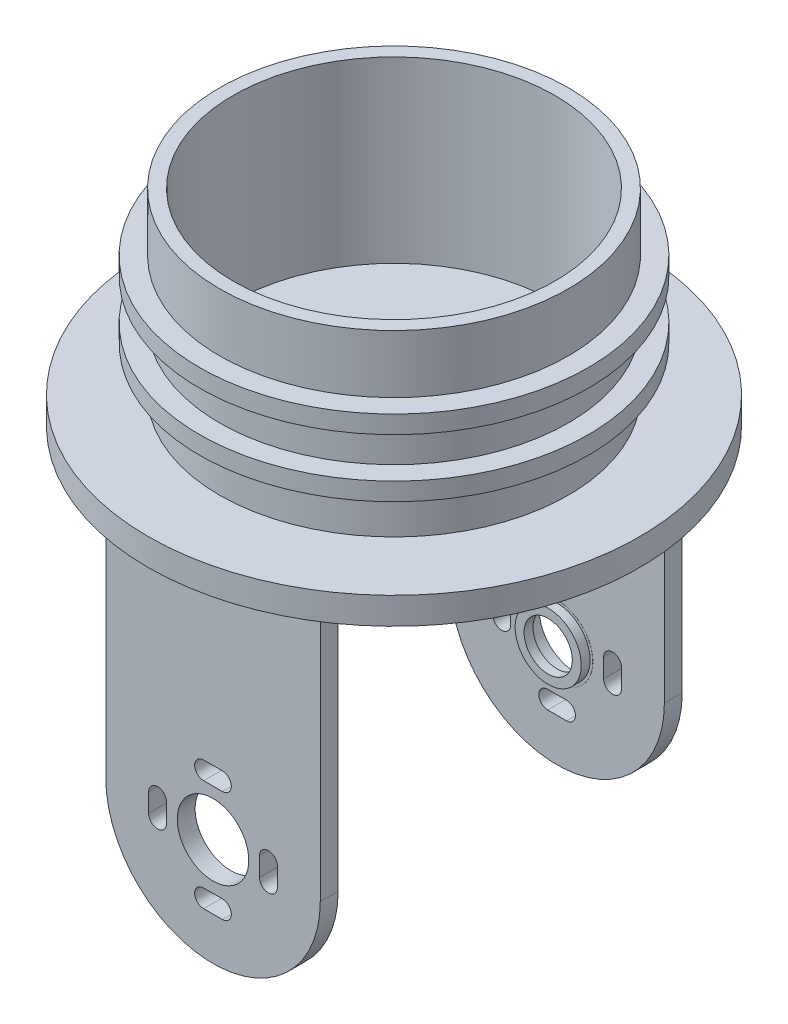
from build123d import *

# Parameters (mm, degrees)
SKETCH_1_R               = 19.5
SKETCH_1_R_2             = 18
EXTRUDE_1_DEPTH          = 20
SKETCH_3_R               = 27.5
EXTRUDE_2_DEPTH          = 3
SKETCH_25_R              = 21.75
SKETCH_25_R_2            = 19.5
EXTRUDE_12_DEPTH         = 2
EXTRUDE_START            = -1
SKETCH_26_R              = 21.75
SKETCH_26_R_2            = 19.5
EXTRUDE_13_DEPTH         = 2
SKETCH_28_R              = 4
EXTRUDE_14_DEPTH         = 2
PATTERN_LINEAR_1_COUNT   = 2
PATTERN_LINEAR_1_PITCH   = 38.5
SKETCH_30_W              = 11
SKETCH_30_H              = 7
EXTRUDE_16_DEPTH         = 10
SKETCH_29_W              = 9
SKETCH_29_H              = 5
CUT_EXTRUDE_2_DEPTH      = 10
CUT_EXTRUDE_2_DEPTH_BACK = 10
SKETCH_31_R              = 3.7
SKETCH_31_R_2            = 2.7
EXTRUDE_17_DEPTH         = 1
SKETCH_32_R              = 4
SKETCH_32_R_2            = 3.7
EXTRUDE_18_DEPTH         = 0.01
SKETCH_33_R              = 6.3
SKETCH_33_R_2            = 4.8
EXTRUDE_19_DEPTH         = 10.5
SKETCH_35_R              = 4.8
CUT_EXTRUDE_3_DEPTH      = 8
SKETCH_36_W              = 2
SKETCH_36_H              = 3.879537943
CUT_EXTRUDE_4_DEPTH      = 3


with BuildPart() as part:
    # 草圖1 → 填料-伸長1 (new body)
    with BuildSketch(Plane(origin=(0, 0, 0), x_dir=(1, 0, 0), z_dir=(0, 1, 0))):
        Circle(SKETCH_1_R)
        Circle(SKETCH_1_R_2, mode=Mode.SUBTRACT)
    extrude(amount=EXTRUDE_1_DEPTH)

    # 草圖3 → 填料-伸長2 (add)
    with BuildSketch(Plane.XZ):
        Circle(SKETCH_3_R)
    extrude(amount=EXTRUDE_2_DEPTH)

    # 草圖25 → 填料-伸長12 (add)
    with BuildSketch(Plane(origin=(0, 7, 0), x_dir=(-1, 0, 0), z_dir=(0, -1, 0))):
        Circle(SKETCH_25_R)
        Circle(SKETCH_25_R_2, mode=Mode.SUBTRACT)
    extrude(amount=EXTRUDE_12_DEPTH)

    # 草圖26 → 填料-伸長13 (add)
    with BuildSketch(Plane(origin=(0, 10.5, 0), x_dir=(-1, 0, 0), z_dir=(0, -1, 0)).offset(EXTRUDE_START)):
        Circle(SKETCH_26_R)
        Circle(SKETCH_26_R_2, mode=Mode.SUBTRACT)
    extrude(amount=-EXTRUDE_13_DEPTH)

    # 草圖28 → 填料-伸長14 (add)
    with BuildSketch(Plane.XY.offset(-18.25)):
        with BuildLine():
            Line((-12, -3), (12, -3))
            Line((12, -3), (12, -33))
            ThreePointArc((12, -33), (0, -45), (-12, -33))
            Line((-12, -33), (-12, -3))
        make_face()
        with Locations((0, -33)):
            Circle(SKETCH_28_R, mode=Mode.SUBTRACT)
        with BuildLine():
            Line((-1.05, -25.8), (1.05, -25.8))
            ThreePointArc((1.05, -25.8), (2.05, -26.8), (1.05, -27.8))
            Line((1.05, -27.8), (-1.05, -27.8))
            ThreePointArc((-1.05, -27.8), (-2.05, -26.8), (-1.05, -25.8))
        make_face(mode=Mode.SUBTRACT)
        with BuildLine():
            Line((7.2, -31.95), (7.2, -34.05))
            ThreePointArc((7.2, -34.05), (6.2, -35.05), (5.2, -34.05))
            Line((5.2, -34.05), (5.2, -31.95))
            ThreePointArc((5.2, -31.95), (6.2, -30.95), (7.2, -31.95))
        make_face(mode=Mode.SUBTRACT)
        with BuildLine():
            Line((-1.05, -40.2), (1.05, -40.2))
            ThreePointArc((1.05, -40.2), (2.05, -39.2), (1.05, -38.2))
            Line((1.05, -38.2), (-1.05, -38.2))
            ThreePointArc((-1.05, -38.2), (-2.05, -39.2), (-1.05, -40.2))
        make_face(mode=Mode.SUBTRACT)
        with BuildLine():
            Line((-7.2, -31.95), (-7.2, -34.05))
            ThreePointArc((-7.2, -34.05), (-6.2, -35.05), (-5.2, -34.05))
            Line((-5.2, -34.05), (-5.2, -31.95))
            ThreePointArc((-5.2, -31.95), (-6.2, -30.95), (-7.2, -31.95))
        make_face(mode=Mode.SUBTRACT)
    extrude_14 = extrude(amount=-EXTRUDE_14_DEPTH)

    # 直線複製排列1: 填料-伸長14 ×2
    with Locations(*[(0, 0, i * PATTERN_LINEAR_1_PITCH) for i in range(1, PATTERN_LINEAR_1_COUNT)]):
        add(extrude_14)

    # 草圖30 → 填料-伸長16 (add)
    with BuildSketch(Plane(origin=(0, 0, 0), x_dir=(1, 0, 0), z_dir=(0, 1, 0))):
        with Locations((0, -12.44566721)):
            Rectangle(SKETCH_30_W, SKETCH_30_H)
    extrude(amount=EXTRUDE_16_DEPTH)

    # 草圖29 → 除料-伸長2 (cut, two sides)
    with BuildSketch(Plane(origin=(0, 0, 0), x_dir=(1, 0, 0), z_dir=(0, 1, 0))) as cut_extrude_2_sk:
        with Locations((0, -12.44566721)):
            Rectangle(SKETCH_29_W, SKETCH_29_H)
    extrude(amount=CUT_EXTRUDE_2_DEPTH, mode=Mode.SUBTRACT)
    extrude(cut_extrude_2_sk.sketch, amount=-CUT_EXTRUDE_2_DEPTH_BACK, mode=Mode.SUBTRACT)

    # 草圖33 → 填料-伸長19 (add)
    with BuildSketch(Plane(origin=(0, 0, -20.25), x_dir=(-1, 0, 0), z_dir=(0, 0, -1))):
        with Locations((0, -10.5)):
            Circle(SKETCH_33_R)
        with Locations((0, -10.5)):
            Circle(SKETCH_33_R_2, mode=Mode.SUBTRACT)
    extrude(amount=EXTRUDE_19_DEPTH)

    # 草圖35 → 除料-伸長3 (cut)
    with BuildSketch(Plane(origin=(0, 0, -20.25), x_dir=(-1, 0, 0), z_dir=(0, 0, -1))):
        with Locations((0, -10.5)):
            Circle(SKETCH_35_R)
    extrude(amount=-CUT_EXTRUDE_3_DEPTH, mode=Mode.SUBTRACT)

    # 草圖36 → 除料-伸長4 (cut)
    with BuildSketch(Plane(origin=(0, 0, -30.75), x_dir=(-1, 0, 0), z_dir=(0, 0, -1))):
        with Locations((0, -16.013198695)):
            Rectangle(SKETCH_36_W, SKETCH_36_H)
    extrude(amount=-CUT_EXTRUDE_4_DEPTH, mode=Mode.SUBTRACT)


with BuildPart() as body_2:
    # 草圖31 → 填料-伸長17 (new body)
    with BuildSketch(Plane.XY.offset(-18.25)):
        with Locations((0, -33)):
            Circle(SKETCH_31_R)
        with Locations((0, -33)):
            Circle(SKETCH_31_R_2, mode=Mode.SUBTRACT)
    extrude(amount=EXTRUDE_17_DEPTH)

    # 草圖32 → 填料-伸長18 (add)
    with BuildSketch(Plane.XY.offset(-18.25)):
        with Locations((0, -33)):
            Circle(SKETCH_32_R)
        with Locations((0, -33)):
            Circle(SKETCH_32_R_2, mode=Mode.SUBTRACT)
    extrude(amount=EXTRUDE_18_DEPTH)


solid = Compound([part.part, body_2.part])
